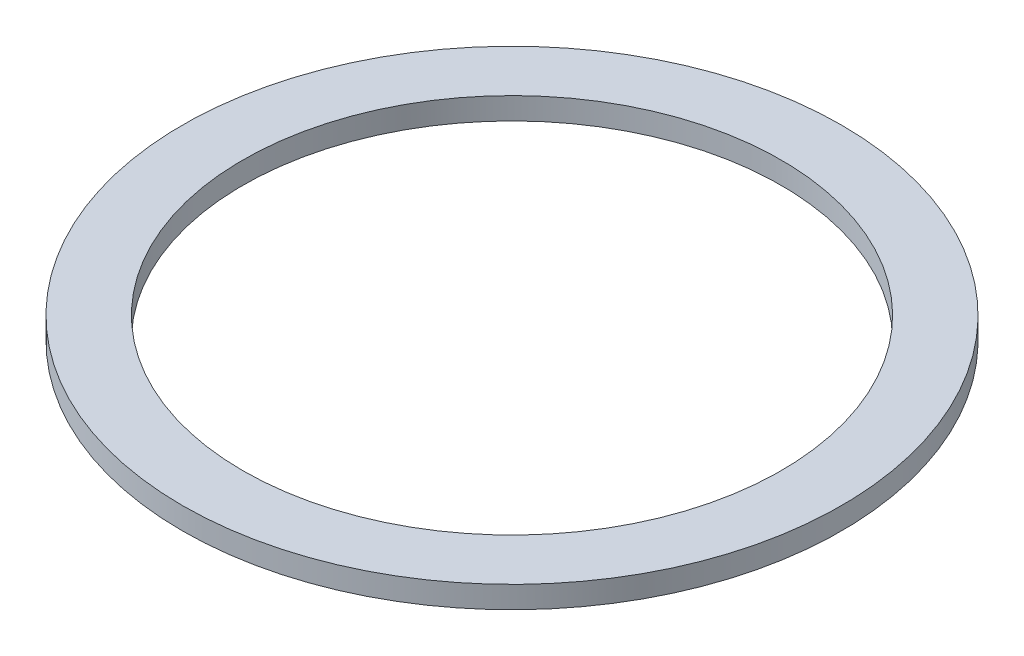
from build123d import *

# Parameters (mm, degrees)
SKETCH1_R           = 15
SKETCH1_R_2         = 12.25
BOSS_EXTRUDE1_DEPTH = 1


with BuildPart() as part:
    # Sketch1 → Boss-Extrude1 (new body)
    with BuildSketch(Plane(origin=(0, 0, 0), x_dir=(-1, 0, 0), z_dir=(0, 1, 0))):
        Circle(SKETCH1_R)
        Circle(SKETCH1_R_2, mode=Mode.SUBTRACT)
    extrude(amount=BOSS_EXTRUDE1_DEPTH)


solid = part.part
